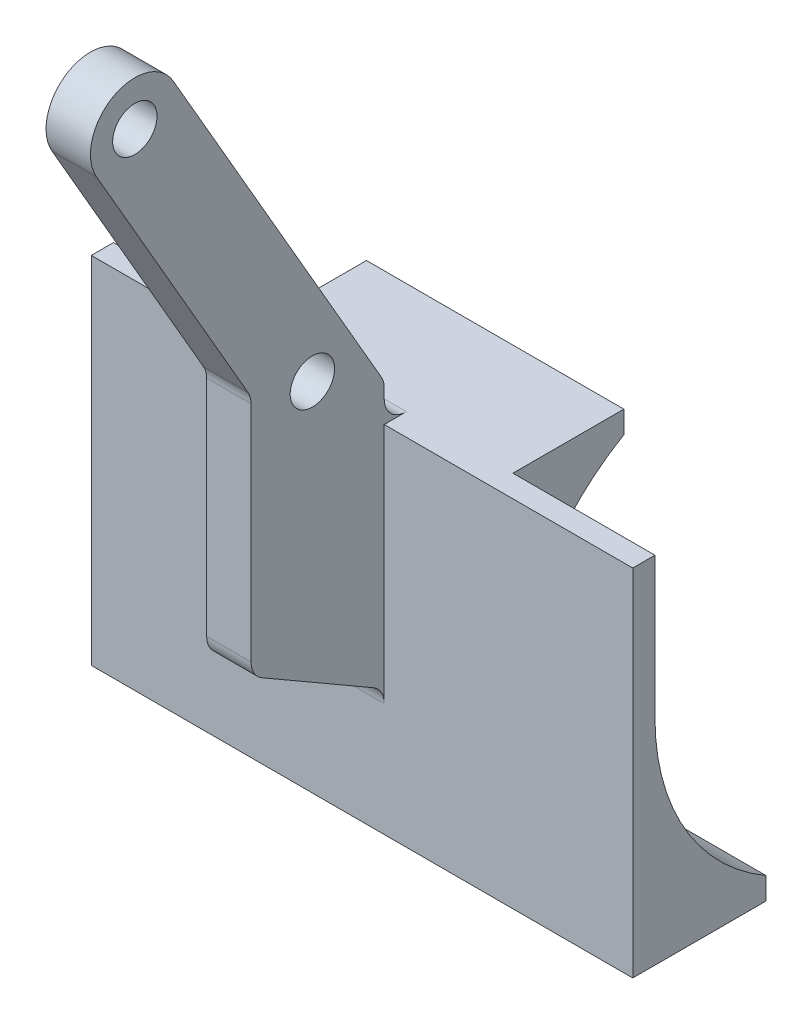
from build123d import *

# Parameters (mm, degrees)
BOSS_EXTRUDE1_DEPTH = 76.2
CUT_EXTRUDE1_START  = 38.1
CUT_EXTRUDE1_DEPTH  = 38.1
BOSS_EXTRUDE5_DEPTH = 38.1
SKETCH5_R           = 6.35
BOSS_EXTRUDE6_DEPTH = 6.35
FILLET1_R           = 6.35
CUT_EXTRUDE3_DEPTH  = 2.54


with BuildPart() as part:
    # Sketch1 → Boss-Extrude1 (new, symmetric)
    with BuildSketch(Plane(origin=(0, 0, 0), x_dir=(0, 0, -1), z_dir=(1, 0, 0))):
        with BuildLine():
            Line((0, 50.8), (38.1, 50.8))
            Line((38.1, 50.8), (38.1, 44.45))
            ThreePointArc((38.1, 44.45), (14.85738686, 21.20738686), (6.35, -10.54261314))
            Line((6.35, -10.54261314), (6.35, -50.8))
            Line((6.35, -50.8), (0, -50.8))
            Line((0, -50.8), (0, 50.8))
        make_face()
    extrude(amount=BOSS_EXTRUDE1_DEPTH, both=True)

    # Sketch6 → Cut-Extrude1 (cut)
    with BuildSketch(Plane(origin=(39.37, 0, 0), x_dir=(0, 0, -1), z_dir=(1, 0, 0)).offset(CUT_EXTRUDE1_START)):
        with BuildLine():
            Line((0, -50.8), (6.35, -50.8))
            Line((6.35, -50.8), (6.35, -10.54261314))
            ThreePointArc((6.35, -10.54261314), (14.85738686, 21.20738686), (38.1, 44.45))
            Line((38.1, 44.45), (38.1, 50.8))
            Line((38.1, 50.8), (0, 50.8))
            Line((0, 50.8), (0, -50.8))
        make_face()
    cut_extrude1 = extrude(amount=-CUT_EXTRUDE1_DEPTH, mode=Mode.SUBTRACT)

    # Mirror1: Cut-Extrude1 across plane
    add(cut_extrude1.mirror(Plane(origin=(0, 0, 0), x_dir=(0, 0, 1), z_dir=(1, 0, 0))), mode=Mode.SUBTRACT)

    # Sketch7 → Boss-Extrude5 (add)
    with BuildSketch(Plane(origin=(39.37, 0, 0), x_dir=(0, 0, -1), z_dir=(1, 0, 0))):
        with BuildLine():
            Line((0, 50.8), (0, -50.8))
            Line((0, -50.8), (38.1, -50.8))
            Line((38.1, -50.8), (38.1, -44.45))
            ThreePointArc((38.1, -44.45), (14.85738686, -21.20738686), (6.35, 10.54261314))
            Line((6.35, 10.54261314), (6.35, 50.8))
            Line((6.35, 50.8), (0, 50.8))
        make_face()
    boss_extrude5 = extrude(amount=BOSS_EXTRUDE5_DEPTH)

    # Mirror2: Boss-Extrude5 across plane
    add(boss_extrude5.mirror(Plane(origin=(0, 0, 0), x_dir=(0, 0, 1), z_dir=(1, 0, 0))))

    # Sketch5 → Boss-Extrude6 (add, symmetric)
    with BuildSketch(Plane(origin=(0, 0, 0), x_dir=(0, 0, -1), z_dir=(1, 0, 0))):
        with BuildLine():
            Line((-82.357309978, 153.382348419), (-38.1, 76.726438931))
            Line((-38.1, 76.726438931), (-38.1, 7.332348419))
            Line((-38.1, 7.332348419), (0, -14.664696837))
            Line((0, -14.664696837), (0, 14.664696837))
            Line((0, 14.664696837), (0, 61.535303163))
            Line((0, 61.535303163), (-60.360264722, 166.082348419))
            ThreePointArc((-60.360264722, 166.082348419), (-77.70878735, 170.730871047), (-82.357309978, 153.382348419))
        make_face()
        with Locations((-71.35878735, 159.732348419)):
            Circle(SKETCH5_R, mode=Mode.SUBTRACT)
        with Locations((-20.55878735, 71.744167394)):
            Circle(SKETCH5_R, mode=Mode.SUBTRACT)
    extrude(amount=BOSS_EXTRUDE6_DEPTH, both=True)

    # Fillet1
    fillet1_edges = [part.edges().sort_by_distance(p)[0] for p in [
        (0, 50.8, 0),
        (0, 61.535303163, 0),
        (0, -14.664696837, 0),
        (0, 7.332348419, 38.1),
        (0, 76.726438931, 38.1),
    ]]
    fillet(fillet1_edges, radius=FILLET1_R)

    # Sketch9 → Cut-Extrude3 (cut)
    with BuildSketch(Plane(origin=(39.37, 0, 0), x_dir=(0, 0, -1), z_dir=(1, 0, 0))):
        with BuildLine():
            Line((38.1, 50.8), (6.35, 50.8))
            Line((6.35, 50.8), (6.35, -10.54261314))
            ThreePointArc((6.35, -10.54261314), (6.570705119, -5.252921341), (7.231286278, 0))
            ThreePointArc((7.231286278, 0), (17.693368999, 25.678041777), (38.1, 44.45))
            Line((38.1, 44.45), (38.1, 50.8))
        make_face()
    cut_extrude3 = extrude(amount=-CUT_EXTRUDE3_DEPTH, mode=Mode.SUBTRACT)

    # Mirror5: Cut-Extrude3 across plane
    add(cut_extrude3.mirror(Plane(origin=(0, 0, 0), x_dir=(0, 0, 1), z_dir=(1, 0, 0))), mode=Mode.SUBTRACT)


solid = part.part
